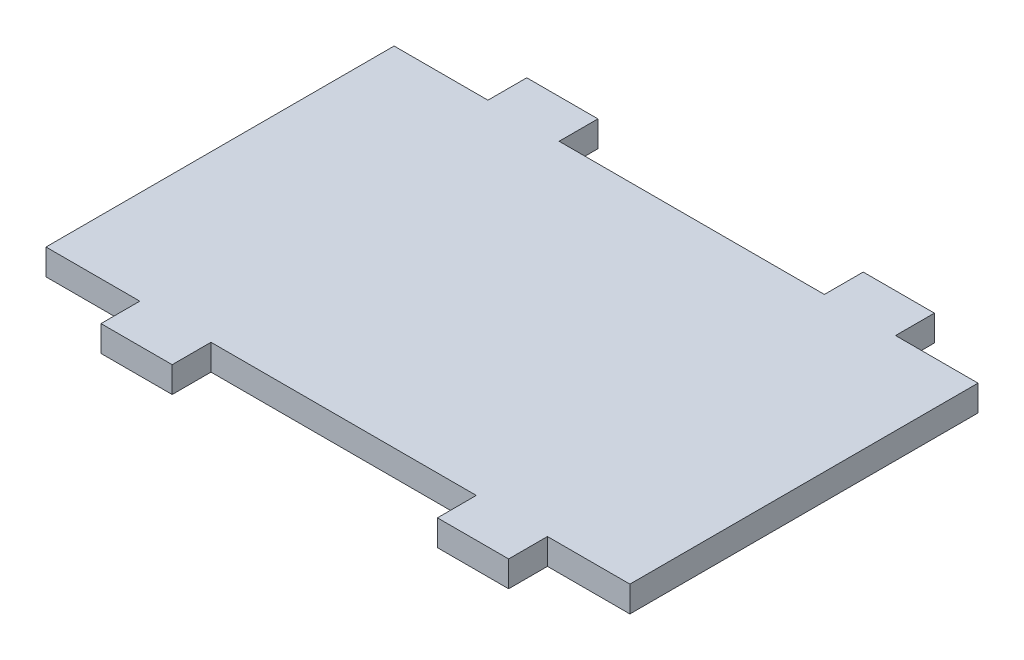
from build123d import *

# Parameters (mm, degrees)
SKETCH1_W           = 22.56
SKETCH1_H           = 13.45
BOSS_EXTRUDE1_DEPTH = 1
SKETCH2_W           = 2.75
SKETCH2_H           = 1.5
BOSS_EXTRUDE2_DEPTH = 1


with BuildPart() as part:
    # Sketch1 → Boss-Extrude1 (new body)
    with BuildSketch(Plane(origin=(0, 0, 0), x_dir=(1, 0, 0), z_dir=(0, 1, 0))):
        with Locations((-39.518423651, -12.055454233)):
            Rectangle(SKETCH1_W, SKETCH1_H)
    extrude(amount=BOSS_EXTRUDE1_DEPTH)

    # Sketch2 → Boss-Extrude2 (add)
    with BuildSketch(Plane(origin=(0, 0, 0), x_dir=(1, 0, 0), z_dir=(0, 1, 0))):
        with Locations((-45.798423651, -4.580454233)):
            Rectangle(SKETCH2_W, SKETCH2_H)
        with Locations((-45.798423651, -19.530454233)):
            Rectangle(SKETCH2_W, SKETCH2_H)
        with Locations((-32.798423651, -4.580454233)):
            Rectangle(SKETCH2_W, SKETCH2_H)
        with Locations((-32.798423651, -19.530454233)):
            Rectangle(SKETCH2_W, SKETCH2_H)
    extrude(amount=BOSS_EXTRUDE2_DEPTH)


solid = part.part
